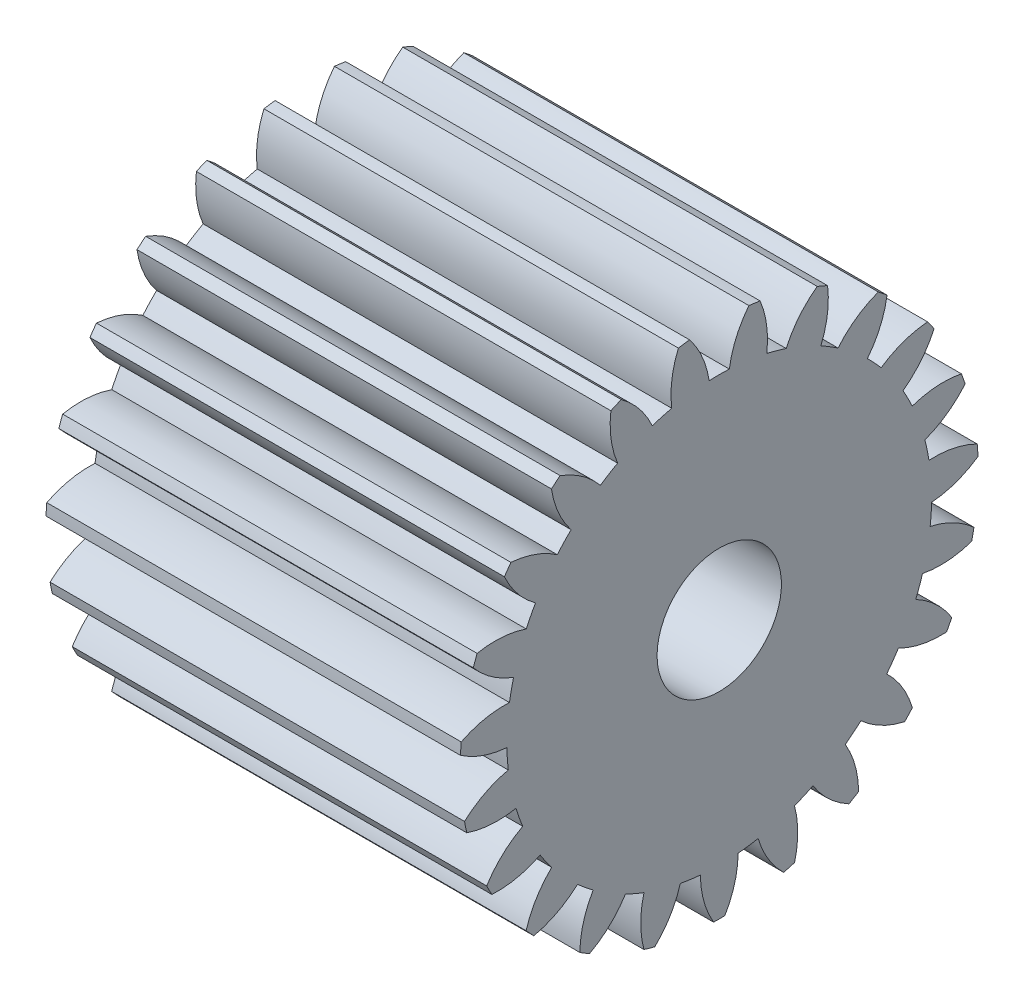
from build123d import *

# Parameters (mm, degrees)
BASPROSKE_W     = 10
BASPROSKE_H     = 6.25
TOOTHCUT_DEPTH  = 14.346347815
TEETHCUTS_COUNT = 23
TEETHCUTS_ANGLE = 344.347826087
BORSKE_R        = 1.5
BORE_DEPTH      = 50.0000508


with BuildPart() as part:
    # BasProSke → Base-Revolve (revolve)
    with BuildSketch(Plane(origin=(0, 0, 0), x_dir=(1, 0, 0), z_dir=(0, 1, 0)), mode=Mode.PRIVATE) as base_revolve_sk:
        with Locations((5, 3.125)):
            Rectangle(BASPROSKE_W, BASPROSKE_H)
    revolve(base_revolve_sk.sketch.rotate(Axis((-10, 0, 0), (1, 0, 0)), 180), axis=Axis((-10, 0, 0), (1, 0, 0)))

    # TooCutSke → ToothCut (cut, through all)
    with BuildSketch(Plane(origin=(0, 0, 0), x_dir=(0, 0, -1), z_dir=(1, 0, 0))):
        with BuildLine():
            ThreePointArc((0.243463669, 5.118212719), (0, 5.124), (-0.243463669, 5.118212719))
            ThreePointArc((-0.243463669, 5.118212719), (-0.414018148, 5.708323155), (-0.734679929, 6.232246029))
            ThreePointArc((-0.734679929, 6.232246029), (0, 6.2754), (0.734679929, 6.232246029))
            ThreePointArc((0.734679929, 6.232246029), (0.414018148, 5.708323155), (0.243463669, 5.118212719))
        make_face()
    toothcut = extrude(amount=TOOTHCUT_DEPTH, mode=Mode.SUBTRACT)

    # TeethCuts: ToothCut ×23 about axis
    teethcuts_axis = Axis((-10, 0, 0), (1, 0, 0))
    for i in range(1, TEETHCUTS_COUNT):
        add(toothcut.rotate(teethcuts_axis, i * TEETHCUTS_ANGLE / (TEETHCUTS_COUNT - 1)), mode=Mode.SUBTRACT)

    # BorSke → Bore (cut, symmetric)
    with BuildSketch(Plane(origin=(0, 0, 0), x_dir=(0, 0, -1), z_dir=(1, 0, 0))):
        with Locations(Location((0, 0, 0), (0, 0, 180))):
            Circle(BORSKE_R)
    extrude(amount=BORE_DEPTH, both=True, mode=Mode.SUBTRACT)


solid = part.part
